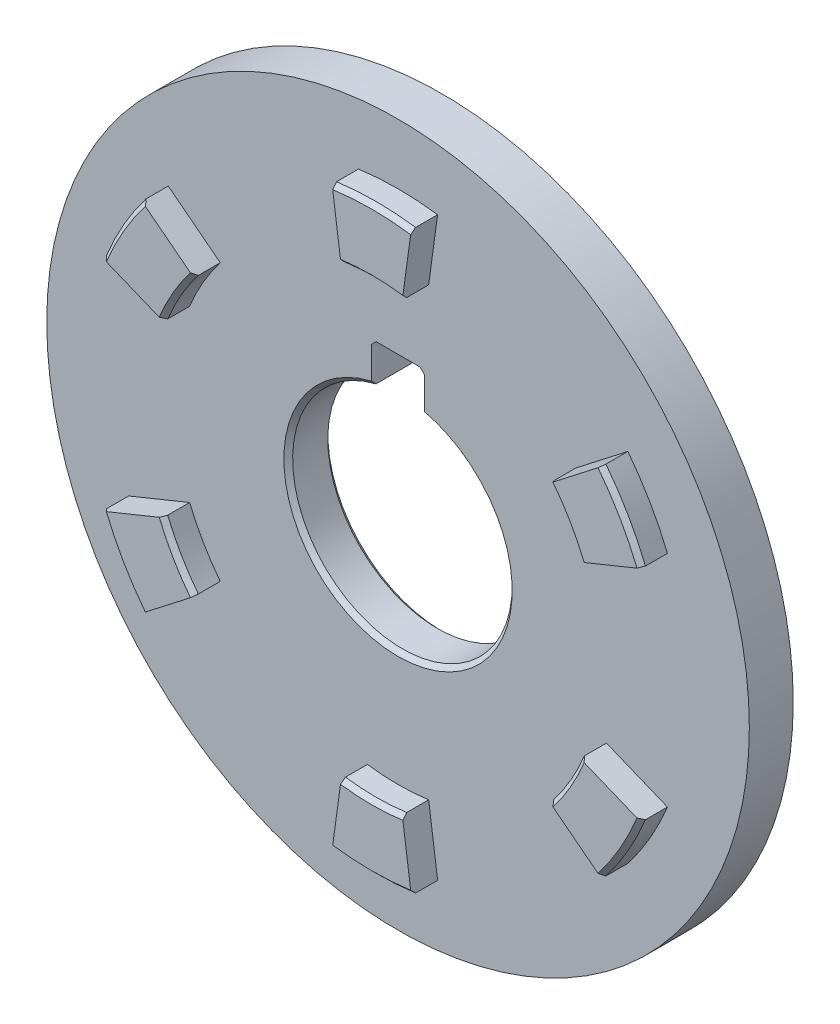
from build123d import *

# Parameters (mm, degrees)
SKETCH1_R                = 80
BOSS_EXTRUDE1_DEPTH      = 5
BOSS_EXTRUDE2_DEPTH      = 6
CHAMFER1_SIZE            = 1
CHAMFER1_OF_MIRROR1_SIZE = 1
CHAMFER2_SIZE            = 1
CHAMFER3_SIZE            = 1


with BuildPart() as part:
    # Sketch1 → Boss-Extrude1 (new body, symmetric)
    with BuildSketch(Plane.XY):
        Circle(SKETCH1_R)
        with BuildLine():
            Line((6, 24.269322199), (6, 33.6))
            Line((6, 33.6), (-6, 33.6))
            Line((-6, 33.6), (-6, 24.269322199))
            ThreePointArc((-6, 24.269322199), (0, -25), (6, 24.269322199))
        make_face(mode=Mode.SUBTRACT)
    extrude(amount=BOSS_EXTRUDE1_DEPTH, both=True)

    # Sketch2 → Boss-Extrude2 (add)
    with BuildSketch(Plane.XY.offset(5)):
        with BuildLine():
            ThreePointArc((-6.97050931, 50.773757985), (0, 51.25), (6.97050931, 50.773757985))
            Line((6.97050931, 50.773757985), (9.010658377, 65.634370079))
            ThreePointArc((9.010658377, 65.634370079), (0, 66.25), (-9.010658377, 65.634370079))
            Line((-9.010658377, 65.634370079), (-6.97050931, 50.773757985))
        make_face()
        with BuildLine():
            ThreePointArc((40.486109606, 31.423517133), (44.383801944, 25.625), (47.456618916, 19.350240853))
            Line((47.456618916, 19.350240853), (61.346361038, 25.01372598))
            ThreePointArc((61.346361038, 25.01372598), (57.374183001, 33.125), (52.335702661, 40.620644098))
            Line((52.335702661, 40.620644098), (40.486109606, 31.423517133))
        make_face()
        with BuildLine():
            ThreePointArc((47.456618916, -19.350240853), (44.383801944, -25.625), (40.486109606, -31.423517133))
            Line((40.486109606, -31.423517133), (52.335702661, -40.620644098))
            ThreePointArc((52.335702661, -40.620644098), (57.374183001, -33.125), (61.346361038, -25.01372598))
            Line((61.346361038, -25.01372598), (47.456618916, -19.350240853))
        make_face()
        with BuildLine():
            ThreePointArc((6.97050931, -50.773757985), (0, -51.25), (-6.97050931, -50.773757985))
            Line((-6.97050931, -50.773757985), (-9.010658377, -65.634370079))
            ThreePointArc((-9.010658377, -65.634370079), (0, -66.25), (9.010658377, -65.634370079))
            Line((9.010658377, -65.634370079), (6.97050931, -50.773757985))
        make_face()
        with BuildLine():
            ThreePointArc((-40.486109606, -31.423517133), (-44.383801944, -25.625), (-47.456618916, -19.350240853))
            Line((-47.456618916, -19.350240853), (-61.346361038, -25.01372598))
            ThreePointArc((-61.346361038, -25.01372598), (-57.374183001, -33.125), (-52.335702661, -40.620644098))
            Line((-52.335702661, -40.620644098), (-40.486109606, -31.423517133))
        make_face()
        with BuildLine():
            ThreePointArc((-47.456618916, 19.350240853), (-44.383801944, 25.625), (-40.486109606, 31.423517133))
            Line((-40.486109606, 31.423517133), (-52.335702661, 40.620644098))
            ThreePointArc((-52.335702661, 40.620644098), (-57.374183001, 33.125), (-61.346361038, 25.01372598))
            Line((-61.346361038, 25.01372598), (-47.456618916, 19.350240853))
        make_face()
    boss_extrude2 = extrude(amount=BOSS_EXTRUDE2_DEPTH)

    # Chamfer1
    chamfer1_edges = [part.edges().sort_by_distance(p)[0] for p in [
        (0, 51.25, 11),
        (0, 66.25, 11),
        (44.383801944, 25.625, 11),
        (57.374183001, 33.125, 11),
        (44.383801944, -25.625, 11),
        (57.374183001, -33.125, 11),
        (0, -51.25, 11),
        (0, -66.25, 11),
        (-44.383801944, -25.625, 11),
        (-57.374183001, -33.125, 11),
        (-44.383801944, 25.625, 11),
        (-57.374183001, 33.125, 11),
    ]]
    chamfer(chamfer1_edges, length=CHAMFER1_SIZE)

    # Mirror1: Boss-Extrude2 across plane
    add(boss_extrude2.mirror(Plane.XY))

    # Chamfer1 of Mirror1
    chamfer1_of_mirror1_edges = [part.edges().sort_by_distance(p)[0] for p in [
        (0, 51.25, -11),
        (0, 66.25, -11),
        (44.383801944, 25.625, -11),
        (57.374183001, 33.125, -11),
        (44.383801944, -25.625, -11),
        (57.374183001, -33.125, -11),
        (0, -51.25, -11),
        (0, -66.25, -11),
        (-44.383801944, -25.625, -11),
        (-57.374183001, -33.125, -11),
        (-44.383801944, 25.625, -11),
        (-57.374183001, 33.125, -11),
    ]]
    chamfer(chamfer1_of_mirror1_edges, length=CHAMFER1_OF_MIRROR1_SIZE)

    # Chamfer2
    chamfer2_edges = [part.edges().sort_by_distance(p)[0] for p in [
        (0, -25, 5),
        (0, -25, -5),
    ]]
    chamfer(chamfer2_edges, length=CHAMFER2_SIZE)

    # Chamfer3
    chamfer3_edges = [part.edges().sort_by_distance(p)[0] for p in [
        (6, 33.6, 0),
        (-6, 33.6, 0),
    ]]
    chamfer(chamfer3_edges, length=CHAMFER3_SIZE)


solid = part.part
